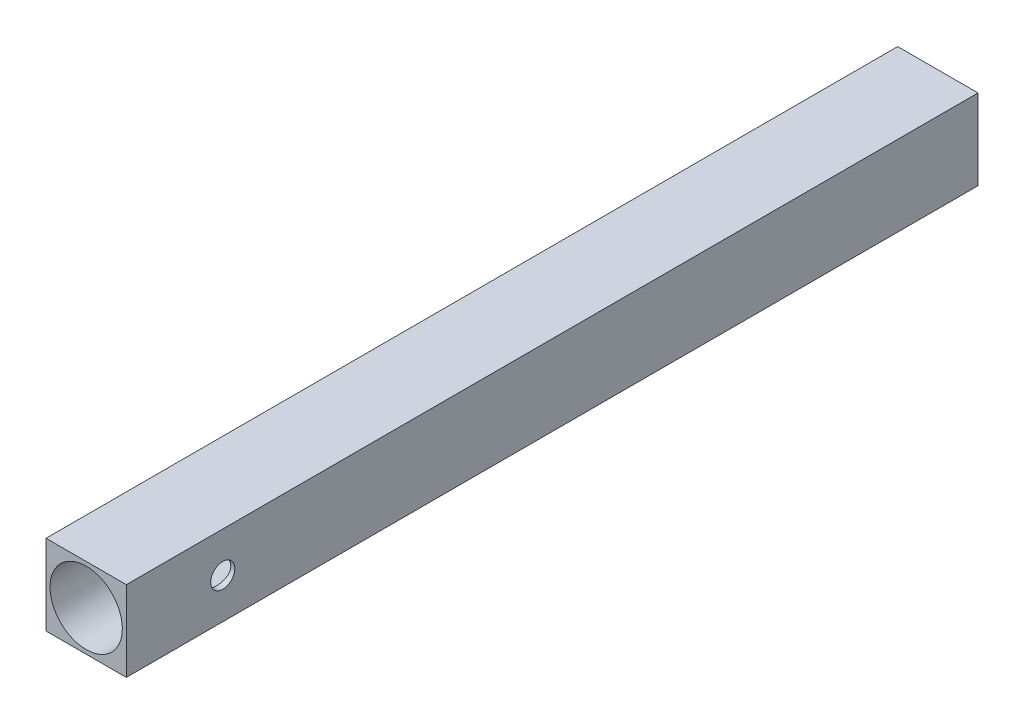
from build123d import *

# Parameters (mm, degrees)
SKETCH_1_W          = 20
SKETCH_1_H          = 20
SKETCH_1_R          = 9
EXTRUDE_1_DEPTH     = 190
SKETCH_2_W          = 20
SKETCH_2_H          = 20
EXTRUDE_2_DEPTH     = 22
SKETCH_4_R          = 3
CUT_EXTRUDE_2_DEPTH = 10


with BuildPart() as part:
    # 草图1 → 凸台-拉伸1 (new body)
    with BuildSketch(Plane.XY):
        Rectangle(SKETCH_1_W, SKETCH_1_H)
        Circle(SKETCH_1_R, mode=Mode.SUBTRACT)
    extrude(amount=EXTRUDE_1_DEPTH)

    # 草图2 → 凸台-拉伸2 (add)
    with BuildSketch(Plane(origin=(0, 0, 0), x_dir=(-1, 0, 0), z_dir=(0, 0, -1))):
        Rectangle(SKETCH_2_W, SKETCH_2_H)
    extrude(amount=EXTRUDE_2_DEPTH)

    # 草图4 → 切除-拉伸2 (cut)
    with BuildSketch(Plane(origin=(10, 0, 0), x_dir=(0, 0, -1), z_dir=(1, 0, 0))):
        with Locations((-166, 0)):
            Circle(SKETCH_4_R)
    extrude(amount=-CUT_EXTRUDE_2_DEPTH, mode=Mode.SUBTRACT)


solid = part.part
